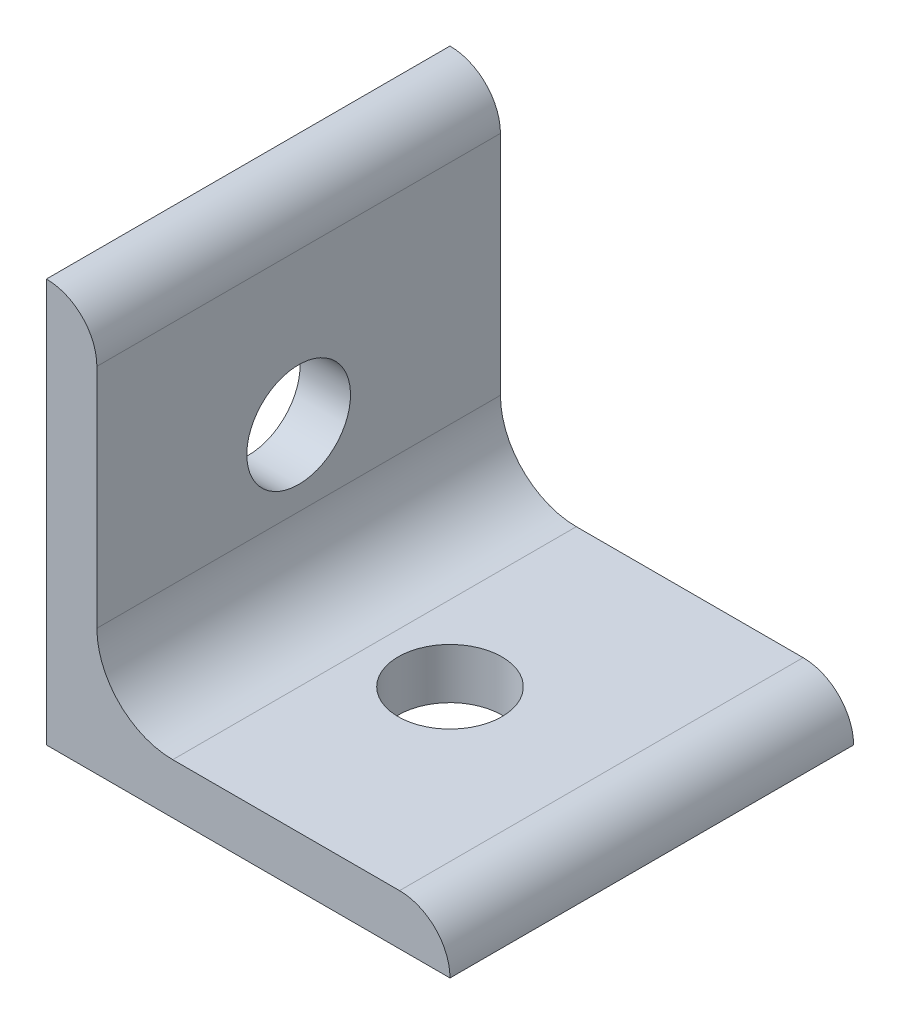
from build123d import *

# Parameters (mm, degrees)
EXTRUDE1_DEPTH     = 25.4
SKETCH2_R          = 3.2639
CUT_EXTRUDE1_DEPTH = 26.4
SKETCH3_R          = 3.2639
CUT_EXTRUDE2_DEPTH = 26.4


with BuildPart() as part:
    # Sketch1 → Extrude1 (new body)
    with BuildSketch(Plane.XY):
        with BuildLine():
            Line((23.473046964, -1.696403207), (23.473046964, -27.096403207))
            Line((23.473046964, -27.096403207), (48.873046964, -27.096403207))
            ThreePointArc((48.873046964, -27.096403207), (47.943110995, -24.851339177), (45.698046964, -23.921403207))
            Line((45.698046964, -23.921403207), (31.423246964, -23.921403207))
            ThreePointArc((31.423246964, -23.921403207), (28.046670663, -22.522779509), (26.648046964, -19.146203207))
            Line((26.648046964, -19.146203207), (26.648046964, -4.871403207))
            ThreePointArc((26.648046964, -4.871403207), (25.718110995, -2.626339177), (23.473046964, -1.696403207))
        make_face()
    extrude(amount=EXTRUDE1_DEPTH)

    # Sketch2 → Cut-Extrude1 (cut, through all)
    with BuildSketch(Plane.ZY.offset(-23.473046964)):
        with Locations((12.7, -14.396403207)):
            Circle(SKETCH2_R)
    extrude(amount=-CUT_EXTRUDE1_DEPTH, mode=Mode.SUBTRACT)

    # Sketch3 → Cut-Extrude2 (cut, through all)
    with BuildSketch(Plane.XZ.offset(27.096403207)):
        with Locations((36.173046964, 12.7)):
            Circle(SKETCH3_R)
    extrude(amount=-CUT_EXTRUDE2_DEPTH, mode=Mode.SUBTRACT)


solid = part.part
